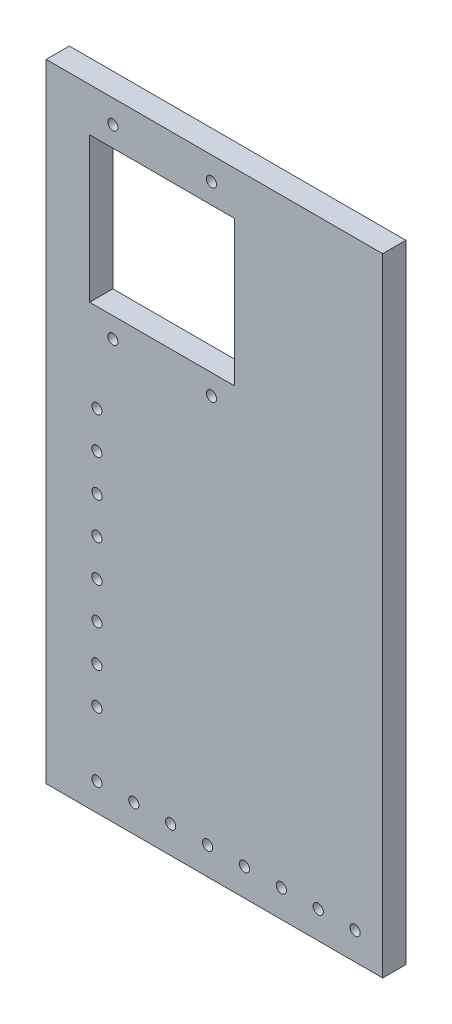
from build123d import *

# Parameters (mm, degrees)
ESBO_O1_W                = 116
ESBO_O1_H                = 216.23
ESBO_O1_R                = 1.75
ESBO_O1_W_2              = 50
ESBO_O1_H_2              = 50
RESSALTO_EXTRUS_O2_DEPTH = 8
ESBO_O2_R                = 1.75
CORTE_EXTRUS_O1_DEPTH    = 100
PADR_O_LINEAR1_COUNT     = 8
PADR_O_LINEAR1_PITCH     = 12.714285714
ESBO_O3_R                = 1.75
CORTE_EXTRUS_O2_DEPTH    = 100
PADR_O_LINEAR2_COUNT     = 8
PADR_O_LINEAR2_PITCH     = 12.714285714


with BuildPart() as part:
    # Esboço1 → Ressalto-extrusão2 (new body)
    with BuildSketch(Plane.XY):
        with Locations((18, -68.115)):
            Rectangle(ESBO_O1_W, ESBO_O1_H)
        with Locations((-17, 32)):
            Circle(ESBO_O1_R, mode=Mode.SUBTRACT)
        with Locations((17, 32)):
            Circle(ESBO_O1_R, mode=Mode.SUBTRACT)
        with Locations((-17, -32)):
            Circle(ESBO_O1_R, mode=Mode.SUBTRACT)
        with Locations((17, -32)):
            Circle(ESBO_O1_R, mode=Mode.SUBTRACT)
        Rectangle(ESBO_O1_W_2, ESBO_O1_H_2, mode=Mode.SUBTRACT)
    extrude(amount=RESSALTO_EXTRUS_O2_DEPTH)

    # Esboço2 → Corte-extrusão1 (cut)
    with BuildSketch(Plane(origin=(0, 0, 0), x_dir=(-1, 0, 0), z_dir=(0, 0, -1))):
        with Locations((-66.5, -166.73)):
            Circle(ESBO_O2_R)
    corte_extrus_o1 = extrude(amount=-CORTE_EXTRUS_O1_DEPTH, mode=Mode.SUBTRACT)

    # Padrão linear1: Corte-extrusão1 ×8
    with Locations(*[(-i * PADR_O_LINEAR1_PITCH, 0, 0) for i in range(1, PADR_O_LINEAR1_COUNT)]):
        add(corte_extrus_o1, mode=Mode.SUBTRACT)

    # Esboço3 → Corte-extrusão2 (cut)
    with BuildSketch(Plane(origin=(0, 0, 0), x_dir=(-1, 0, 0), z_dir=(0, 0, -1))):
        with Locations((22.5, -55.5)):
            Circle(ESBO_O3_R)
    corte_extrus_o2 = extrude(amount=-CORTE_EXTRUS_O2_DEPTH, mode=Mode.SUBTRACT)

    # Padrão linear2: Corte-extrusão2 ×8
    with Locations(*[(0, -i * PADR_O_LINEAR2_PITCH, 0) for i in range(1, PADR_O_LINEAR2_COUNT)]):
        add(corte_extrus_o2, mode=Mode.SUBTRACT)


solid = part.part
